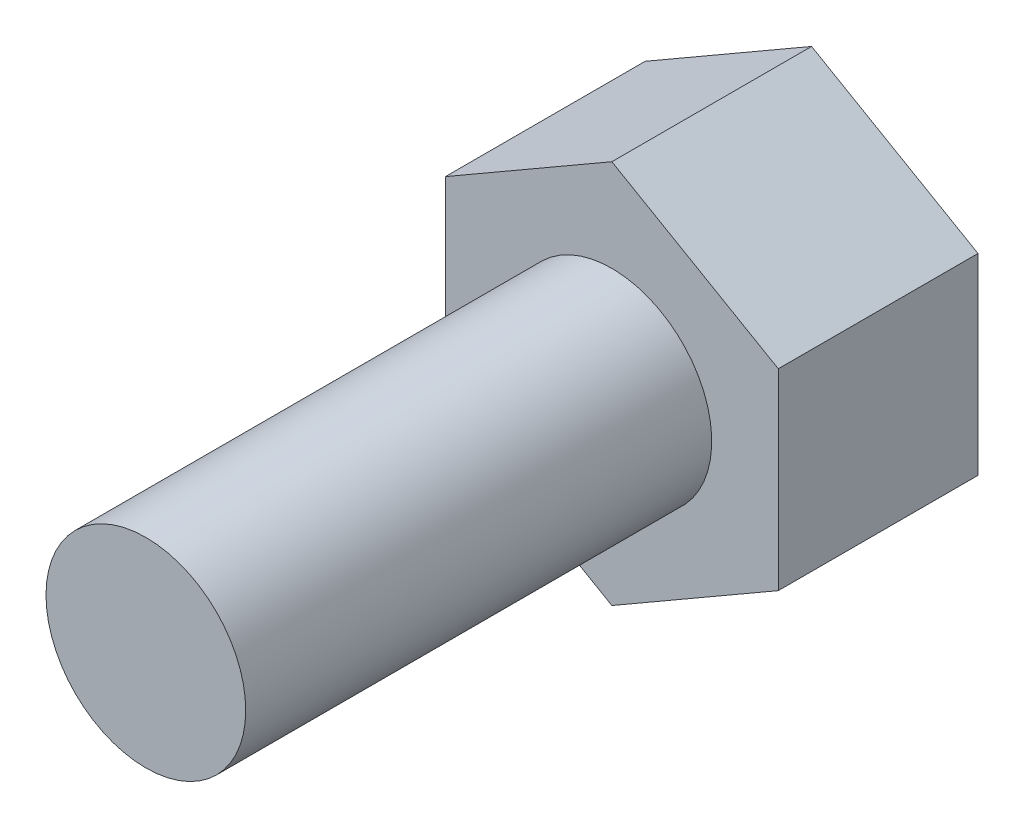
from build123d import *

# Parameters (mm, degrees)
SKETCH1_R           = 1.5
BOSS_EXTRUDE1_DEPTH = 7
BOSS_EXTRUDE2_DEPTH = 3


with BuildPart() as part:
    # Sketch1 → Boss-Extrude1 (new body)
    with BuildSketch(Plane.XY):
        with Locations((-63.49476159, 14.978708134)):
            Circle(SKETCH1_R)
    extrude(amount=BOSS_EXTRUDE1_DEPTH)

    # Sketch2 → Boss-Extrude2 (add)
    with BuildSketch(Plane(origin=(0, 0, 0), x_dir=(-1, 0, 0), z_dir=(0, 0, -1))):
        Polygon((63.49476159, 12.091956788), (65.99476159, 13.535332461), (65.99476159, 16.422083807), (63.49476159, 17.86545948), (60.99476159, 16.422083807), (60.99476159, 13.535332461), align=None)
    extrude(amount=BOSS_EXTRUDE2_DEPTH)


solid = part.part
